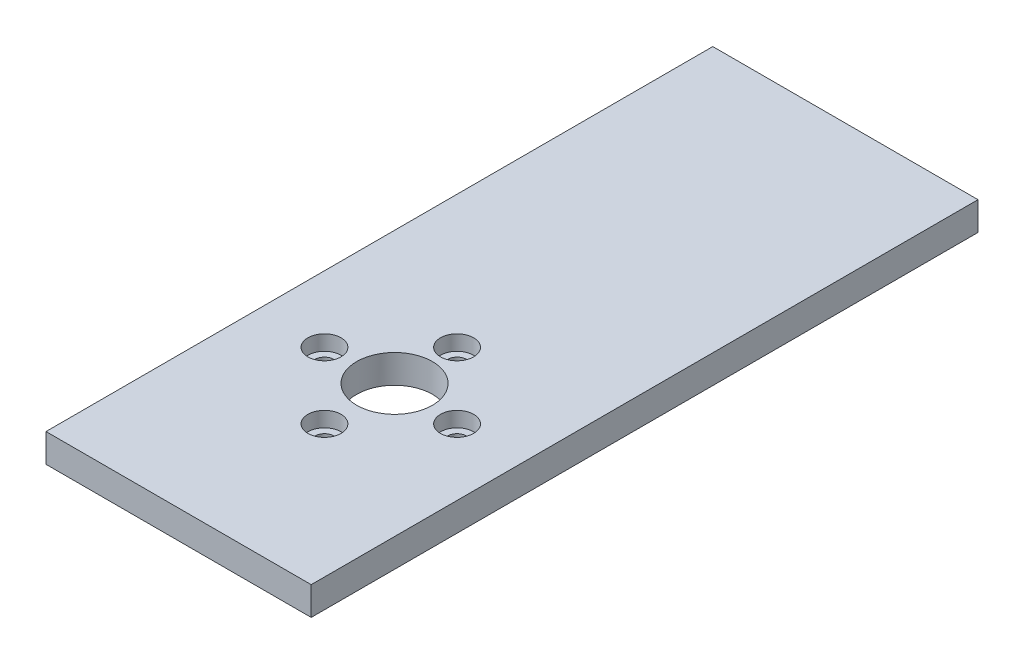
from build123d import *

# Parameters (mm, degrees)
SKETCH1_W           = 28
SKETCH1_H           = 70.4
BOSS_EXTRUDE1_DEPTH = 3
SKETCH4_R           = 1
CUT_EXTRUDE2_DEPTH  = 10
SKETCH5_R           = 4
CUT_EXTRUDE3_DEPTH  = 10
SKETCH10_R          = 1.75
CUT_EXTRUDE9_DEPTH  = 1.6


with BuildPart() as part:
    # Sketch1 → Boss-Extrude1 (new body)
    with BuildSketch(Plane(origin=(0, 0, 0), x_dir=(1, 0, 0), z_dir=(0, 1, 0))):
        Rectangle(SKETCH1_W, SKETCH1_H)
    extrude(amount=BOSS_EXTRUDE1_DEPTH)

    # Sketch4 → Cut-Extrude2 (cut)
    with BuildSketch(Plane(origin=(0, 3, 0), x_dir=(1, 0, 0), z_dir=(0, 1, 0))):
        with Locations((7, -12.8)):
            Circle(SKETCH4_R)
        with Locations((0, -19.8)):
            Circle(SKETCH4_R)
        with Locations((-7, -12.8)):
            Circle(SKETCH4_R)
        with Locations((0, -5.8)):
            Circle(SKETCH4_R)
    extrude(amount=-CUT_EXTRUDE2_DEPTH, mode=Mode.SUBTRACT)

    # Sketch5 → Cut-Extrude3 (cut)
    with BuildSketch(Plane(origin=(0, 3, 0), x_dir=(1, 0, 0), z_dir=(0, 1, 0))):
        with Locations((0, -12.4)):
            Circle(SKETCH5_R)
    extrude(amount=-CUT_EXTRUDE3_DEPTH, mode=Mode.SUBTRACT)

    # Sketch10 → Cut-Extrude9 (cut)
    with BuildSketch(Plane(origin=(0, 3, 0), x_dir=(1, 0, 0), z_dir=(0, 1, 0))):
        with Locations((0, -19.8)):
            Circle(SKETCH10_R)
        with Locations((-7, -12.8)):
            Circle(SKETCH10_R)
        with Locations((0, -5.8)):
            Circle(SKETCH10_R)
        with Locations((7, -12.8)):
            Circle(SKETCH10_R)
    extrude(amount=-CUT_EXTRUDE9_DEPTH, mode=Mode.SUBTRACT)


solid = part.part
